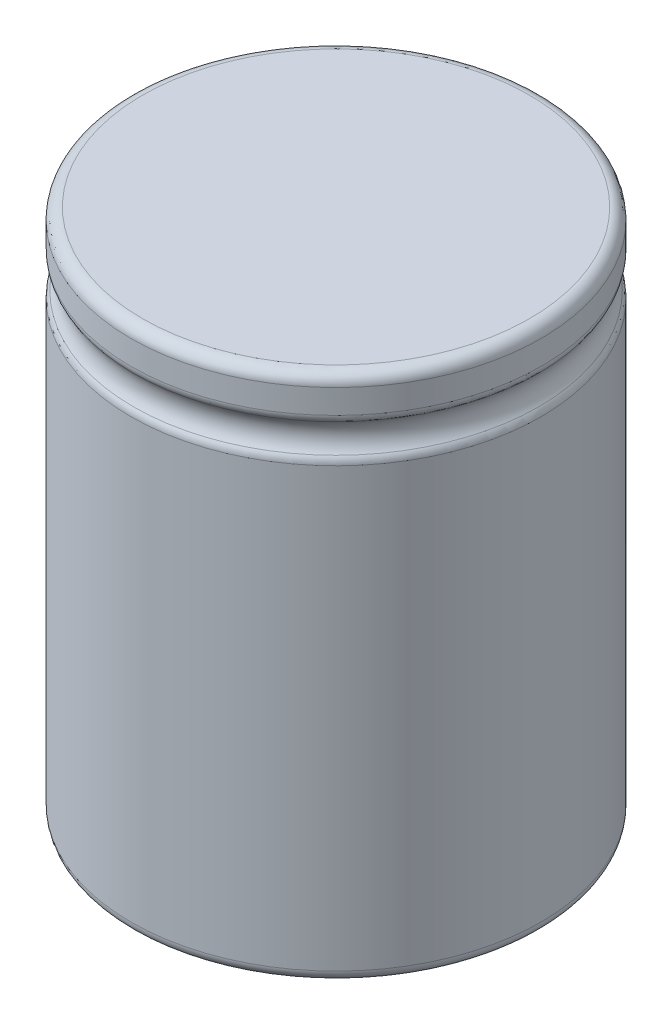
from build123d import *

# Parameters (mm, degrees)
ESBO_O1_R                = 17.85
RESSALTO_EXTRUS_O1_DEPTH = 46
FILETE1_R                = 1
FILETE2_R                = 1


with BuildPart() as part:
    # Esboço1 → Ressalto-extrusão1 (new body)
    with BuildSketch(Plane(origin=(0, 0, 0), x_dir=(1, 0, 0), z_dir=(0, 1, 0))):
        with Locations(Location((0, 0, 0), (0, 0, 270))):
            Circle(ESBO_O1_R)
    extrude(amount=RESSALTO_EXTRUS_O1_DEPTH)

    # Varredura de corte1: sweep along a curve in space
    with BuildLine() as varredura_de_corte1_path:
        ThreePointArc((0, 46, 17.85), (12.621856044, 46, 12.621856044), (17.85, 46, 0))
        ThreePointArc((17.85, 46, 0), (12.621856044, 46, -12.621856044), (0, 46, -17.85))
        ThreePointArc((0, 46, -17.85), (-12.621856044, 46, -12.621856044), (-17.85, 46, 0))
        ThreePointArc((-17.85, 46, 0), (-12.621856044, 46, 12.621856044), (0, 46, 17.85))
    # Esboço2 → Varredura de corte1 (sweep, cut)
    with BuildSketch(Plane.XY):
        with BuildLine():
            Line((17.85, 42.5), (17.85, 39.5))
            ThreePointArc((17.85, 39.5), (17.172875656, 41), (17.85, 42.5))
        make_face()
    sweep(path=varredura_de_corte1_path.line, mode=Mode.SUBTRACT)

    # Filete1
    filete1_edges = [part.edges().sort_by_distance(p)[0] for p in [
        (0, 0, -17.85),
        (0, 46, -17.85),
    ]]
    fillet(filete1_edges, radius=FILETE1_R)

    # Filete2
    filete2_edges = [part.edges().sort_by_distance(p)[0] for p in [
        (12.621856044, 39.5, -12.621856044),
        (12.621856044, 42.5, -12.621856044),
    ]]
    fillet(filete2_edges, radius=FILETE2_R)


solid = part.part
